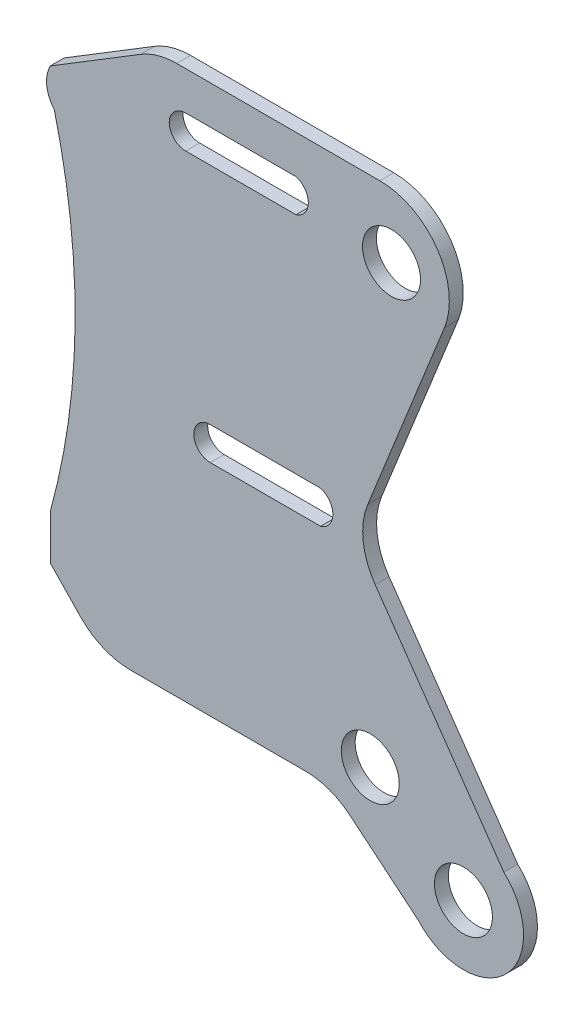
from build123d import *

# Parameters (mm, degrees)
ESBO_O1_R                = 20.863274014
RESSALTO_EXTRUS_O1_DEPTH = 10


with BuildPart() as part:
    # Esboço1 → Ressalto-extrusão1 (new body)
    with BuildSketch(Plane.XY):
        with BuildLine():
            Line((7335.845216731, 5491.256809223), (7400.784408374, 5530.976897315))
            ThreePointArc((7400.784408374, 5530.976897315), (7413.321768246, 5536.451480894), (7426.873657559, 5538.323045473))
            Line((7426.873657559, 5538.323045473), (7573.061256946, 5538.323045473))
            ThreePointArc((7573.061256946, 5538.323045473), (7614.474439212, 5516.339974903), (7619.472065145, 5469.720978859))
            Line((7619.472065145, 5469.720978859), (7564.300408584, 5332.071693766))
            ThreePointArc((7564.300408584, 5332.071693766), (7561.033258012, 5307.80390458), (7569.680866385, 5284.894981989))
            Line((7569.680866385, 5284.894981989), (7662.336085762, 5151.851296041))
            ThreePointArc((7662.336085762, 5151.851296041), (7663.61020686, 5089.017265945), (7600.799568851, 5091.153261173))
            Line((7600.799568851, 5091.153261173), (7551.417263378, 5132.063170982))
            ThreePointArc((7551.417263378, 5132.063170982), (7536.472634142, 5140.597670031), (7519.519540605, 5143.559466201))
            Line((7519.519540605, 5143.559466201), (7393.552869473, 5143.559466201))
            ThreePointArc((7393.552869473, 5143.559466201), (7373.972219734, 5147.552964967), (7357.519382018, 5158.895539969))
            Line((7357.519382018, 5158.895539969), (7335.845216731, 5181.426044959))
            Line((7335.845216731, 5181.426044959), (7335.845216731, 5213.722321046))
            ThreePointArc((7335.845216731, 5213.722321046), (7353.706243942, 5339.368656723), (7338.756279232, 5465.394513266))
            ThreePointArc((7338.756279232, 5465.394513266), (7333.313540231, 5477.876860759), (7335.845216731, 5491.256809223))
        make_face()
        with Locations((7566.174846652, 5169.295330687)):
            Circle(ESBO_O1_R, mode=Mode.SUBTRACT)
        with Locations((7633.216444383, 5119.830887551)):
            Circle(ESBO_O1_R, mode=Mode.SUBTRACT)
        with Locations((7581.43197041, 5491.256809223)):
            Circle(ESBO_O1_R, mode=Mode.SUBTRACT)
        with BuildLine():
            Line((7512.734775832, 5486.974409199), (7433.320588265, 5486.974409199))
            ThreePointArc((7433.320588265, 5486.974409199), (7421.471766691, 5498.823230773), (7433.320588265, 5510.672052347))
            Line((7433.320588265, 5510.672052347), (7512.734775832, 5510.672052347))
            ThreePointArc((7512.734775832, 5510.672052347), (7521.55530344, 5498.823230773), (7512.734775832, 5486.974409199))
        make_face(mode=Mode.SUBTRACT)
        with BuildLine():
            Line((7530.423638246, 5301.620805578), (7451.009450679, 5301.620805578))
            ThreePointArc((7451.009450679, 5301.620805578), (7439.160629105, 5313.469627152), (7451.009450679, 5325.318448726))
            Line((7451.009450679, 5325.318448726), (7530.423638246, 5325.318448726))
            ThreePointArc((7530.423638246, 5325.318448726), (7539.244165855, 5313.469627152), (7530.423638246, 5301.620805578))
        make_face(mode=Mode.SUBTRACT)
    extrude(amount=RESSALTO_EXTRUS_O1_DEPTH)


solid = part.part
